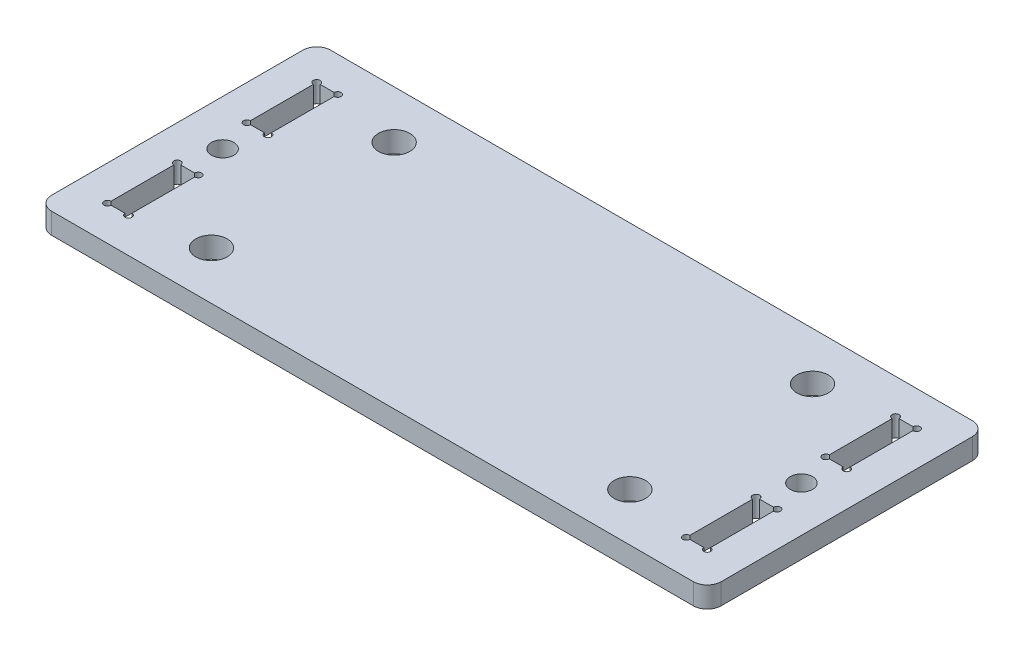
from build123d import *

# Parameters (mm, degrees)
SKETCH1_R           = 2.25
SKETCH1_R_2         = 1.6
SKETCH1_W           = 3
SKETCH1_H           = 10
BOSS_EXTRUDE1_DEPTH = 3
SKETCH2_R           = 0.5
CUT_EXTRUDE1_DEPTH  = 4


with BuildPart() as part:
    # Sketch1 → Boss-Extrude1 (new body)
    with BuildSketch(Plane(origin=(0, 0, 0), x_dir=(1, 0, 0), z_dir=(0, 1, 0))):
        with BuildLine():
            Line((-46, -20), (46, -20))
            ThreePointArc((46, -20), (47.414213562, -19.414213562), (48, -18))
            Line((48, -18), (48, 18))
            ThreePointArc((48, 18), (47.414213562, 19.414213562), (46, 20))
            Line((46, 20), (-46, 20))
            ThreePointArc((-46, 20), (-47.414213562, 19.414213562), (-48, 18))
            Line((-48, 18), (-48, -18))
            ThreePointArc((-48, -18), (-47.414213562, -19.414213562), (-46, -20))
        make_face()
        with Locations((-30, 13.1)):
            Circle(SKETCH1_R, mode=Mode.SUBTRACT)
        with Locations((30, 13.1)):
            Circle(SKETCH1_R, mode=Mode.SUBTRACT)
        with Locations((30, -13.1)):
            Circle(SKETCH1_R, mode=Mode.SUBTRACT)
        with Locations((-30, -13.1)):
            Circle(SKETCH1_R, mode=Mode.SUBTRACT)
        with Locations((41.5, 0)):
            Circle(SKETCH1_R_2, mode=Mode.SUBTRACT)
        with Locations((-41.5, 0)):
            Circle(SKETCH1_R_2, mode=Mode.SUBTRACT)
        with Locations((-41.5, 10)):
            Rectangle(SKETCH1_W, SKETCH1_H, mode=Mode.SUBTRACT)
        with Locations((-41.5, -10)):
            Rectangle(SKETCH1_W, SKETCH1_H, mode=Mode.SUBTRACT)
        with Locations((41.5, 10)):
            Rectangle(SKETCH1_W, SKETCH1_H, mode=Mode.SUBTRACT)
        with Locations((41.5, -10)):
            Rectangle(SKETCH1_W, SKETCH1_H, mode=Mode.SUBTRACT)
    extrude(amount=BOSS_EXTRUDE1_DEPTH)

    # Sketch2 → Cut-Extrude1 (cut, through all)
    with BuildSketch(Plane(origin=(0, 3, 0), x_dir=(1, 0, 0), z_dir=(0, 1, 0))):
        with Locations((-43, 15)):
            Circle(SKETCH2_R)
        with Locations((-40, 15)):
            Circle(SKETCH2_R)
        with Locations((-40, 5)):
            Circle(SKETCH2_R)
        with Locations((-43, 5)):
            Circle(SKETCH2_R)
        with Locations((-43, -5)):
            Circle(SKETCH2_R)
        with Locations((-40, -5)):
            Circle(SKETCH2_R)
        with Locations((-43, -15)):
            Circle(SKETCH2_R)
        with Locations((-40, -15)):
            Circle(SKETCH2_R)
        with Locations((40, -15)):
            Circle(SKETCH2_R)
        with Locations((43, -15)):
            Circle(SKETCH2_R)
        with Locations((43, -5)):
            Circle(SKETCH2_R)
        with Locations((40, -5)):
            Circle(SKETCH2_R)
        with Locations((40, 5)):
            Circle(SKETCH2_R)
        with Locations((43, 5)):
            Circle(SKETCH2_R)
        with Locations((43, 15)):
            Circle(SKETCH2_R)
        with Locations((40, 15)):
            Circle(SKETCH2_R)
    extrude(amount=-CUT_EXTRUDE1_DEPTH, mode=Mode.SUBTRACT)


solid = part.part
